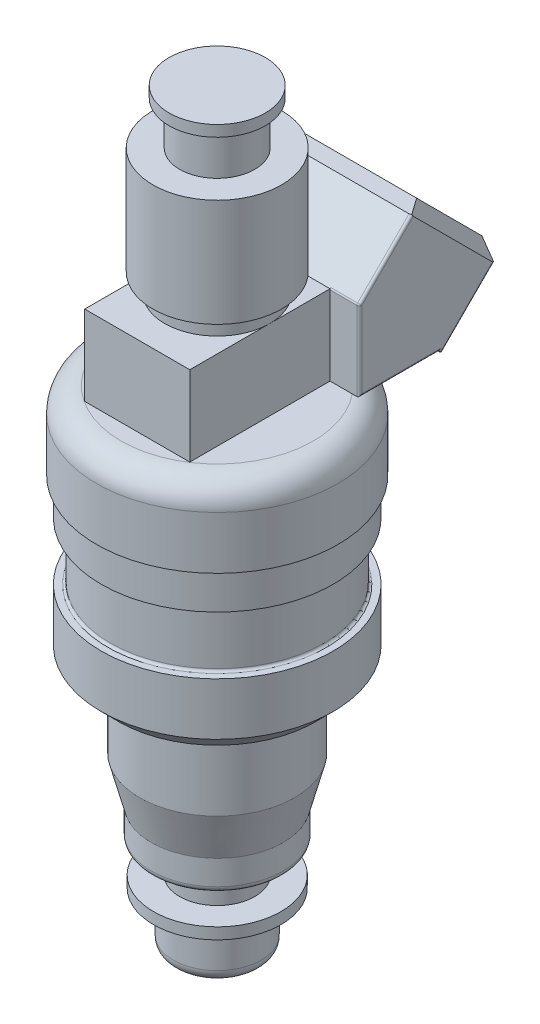
from build123d import *

# Parameters (mm, degrees)
EXTRUDE1_DEPTH      = 8.255
EXTRUDE1_DEPTH_BACK = 6.223
SKETCH2_W           = 10.8458
SKETCH2_H           = 8.255
SKETCH3_W           = 16.891
SKETCH3_H           = 12.065
EXTRUDE2_DEPTH      = 8.89
EXTRUDE3_REACH      = 82.415
SKETCH4_W           = 16.891
SKETCH4_H           = 8.255
CHAMFER1_SIZE       = 1.27
FILLET5_R           = 0.254


with BuildPart() as part:
    # Sketch1 → Revolve1 (revolve)
    with BuildSketch(Plane.XY):
        with BuildLine():
            Line((0, 0), (3.2639, 0))
            ThreePointArc((3.2639, 0), (4.161925612, 0.371974388), (4.5339, 1.27))
            Line((4.5339, 1.27), (4.5339, 5.207))
            ThreePointArc((4.5339, 5.207), (4.608294878, 5.386605122), (4.7879, 5.461))
            Line((4.7879, 5.461), (6.5786, 5.461))
            Line((6.5786, 5.461), (6.5786, 6.6294))
            Line((6.5786, 6.6294), (3.8862, 6.6294))
            Line((3.8862, 6.6294), (3.8862, 9.7282))
            Line((3.8862, 9.7282), (6.1595, 9.7282))
            ThreePointArc((6.1595, 9.7282), (6.608512806, 9.914187194), (6.7945, 10.3632))
            Line((6.7945, 10.3632), (6.7945, 12.9032))
            Line((6.7945, 12.9032), (8.001, 17.530662025))
            Line((8.001, 17.530662025), (8.001, 24.13))
            ThreePointArc((8.001, 24.13), (8.372974388, 25.028025612), (9.271, 25.4))
            Line((9.271, 25.4), (10.167348776, 25.4))
            Line((10.167348776, 25.4), (11.9634, 27.196051224))
            Line((11.9634, 27.196051224), (11.9634, 32.606251224))
            Line((11.9634, 32.606251224), (11.2903, 32.606251224))
            ThreePointArc((11.2903, 32.606251224), (11.110694878, 32.680646102), (11.0363, 32.860251224))
            Line((11.0363, 32.860251224), (11.0363, 38.321251224))
            ThreePointArc((11.0363, 38.321251224), (11.110694878, 38.500856347), (11.2903, 38.575251224))
            Line((11.2903, 38.575251224), (11.9634, 38.575251224))
            Line((11.9634, 38.575251224), (11.9634, 42.385251224))
            Line((11.9634, 42.385251224), (12.4587, 42.385251224))
            Line((12.4587, 42.385251224), (12.4587, 47.8282))
            ThreePointArc((12.4587, 47.8282), (11.714751224, 49.624251224), (9.9187, 50.3682))
            Line((9.9187, 50.3682), (5.4229, 50.3682))
            Line((5.4229, 50.3682), (5.4229, 60.5282))
            Line((5.4229, 60.5282), (6.6421, 60.5282))
            Line((6.6421, 60.5282), (6.6421, 71.628))
            Line((6.6421, 71.628), (3.8735, 71.628))
            Line((3.8735, 71.628), (3.8735, 76.073))
            Line((3.8735, 76.073), (4.9657, 76.073))
            Line((4.9657, 76.073), (4.9657, 77.216))
            Line((4.9657, 77.216), (0, 77.216))
            Line((0, 77.216), (0, 0))
        make_face()
    revolve(axis=Axis((0, 0, 0), (0, 1, 0)))

    # Sketch2 → Extrude1 (add, two sides: drawn at the far end of the back side and taken through both)
    with BuildSketch(Plane.XY.offset(-EXTRUDE1_DEPTH_BACK)):
        with Locations((0, 54.4957)):
            Rectangle(SKETCH2_W, SKETCH2_H)
    extrude(amount=EXTRUDE1_DEPTH + EXTRUDE1_DEPTH_BACK)


with BuildPart() as body_2:
    # Sketch3 → Extrude2 (new body)
    with BuildSketch(Plane(origin=(0, 32.4231, -32.4231), x_dir=(-1, 0, 0), z_dir=(0, 0.7071067811865389, -0.7071067811865562))):
        with Locations((0, 31.020036756)):
            Rectangle(SKETCH3_W, SKETCH3_H)
    extrude(amount=EXTRUDE2_DEPTH)

    # Extrude3: up to this face of the body (flat: up to its plane)
    extrude3_end = Plane(body_2.part.faces().sort_by_distance((0, 54.357578342, -10.488621658))[0])
    # Sketch4 → Extrude3 (add, up to the picked face)
    with BuildSketch(Plane(origin=(0, 0, -6.223), x_dir=(-1, 0, 0), z_dir=(0, 0, -1)), mode=Mode.PRIVATE) as extrude3_sk1:
        with Locations((0, 54.4957)):
            Rectangle(SKETCH4_W, SKETCH4_H)
    extrude3_tool1 = split(extrude(extrude3_sk1.sketch, amount=EXTRUDE3_REACH, mode=Mode.PRIVATE), bisect_by=extrude3_end, keep=Keep.BOTH, mode=Mode.PRIVATE)

    add(part.part)  # Extrude3 merges part
    add(extrude3_tool1.solids().sort_by(Axis((0, 54.4957, -6.223), (0, 0, -1)))[0])

    # Chamfer1
    chamfer1_edges = [body_2.edges().sort_by_distance(p)[0] for p in [
        (8.4455, 60.643757627, -16.774800942),
        (0, 64.909379285, -12.509179285),
        (-8.4455, 60.643757627, -16.774800942),
        (0, 56.37813597, -21.0404226),
    ]]
    chamfer(chamfer1_edges, length=CHAMFER1_SIZE)

    # Fillet5
    fillet5_edges = [body_2.edges().sort_by_distance(p)[0] for p in [
        (-8.4455, 50.3682, -10.3505),
        (8.4455, 50.3682, -10.3505),
        (8.4455, 61.317276836, -8.917076836),
        (8.4455, 54.4957, -6.223),
        (6.9342, 58.6232, -6.223),
        (-6.9342, 58.6232, -6.223),
        (-8.4455, 54.4957, -6.223),
        (-8.4455, 61.317276836, -8.917076836),
        (-8.4455, 50.230078342, -14.616121658),
        (-8.4455, 52.786033521, -17.448320151),
        (8.4455, 50.230078342, -14.616121658),
        (8.4455, 52.786033521, -17.448320151),
    ]]
    fillet(fillet5_edges, radius=FILLET5_R)


solid = body_2.part
